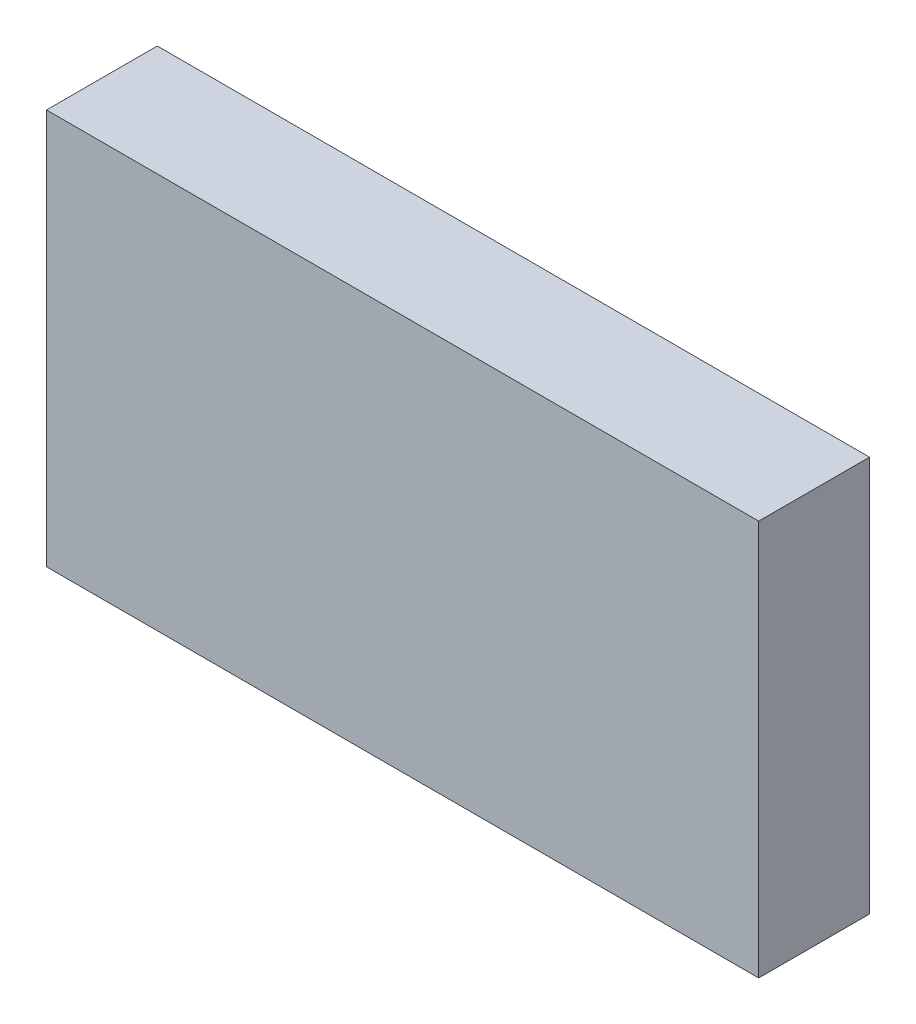
from build123d import *

# Parameters (mm, degrees)
PEDOUTLINE_W               = 114.3
PEDOUTLINE_H               = 63.5
PEDOUTLINE_THICKNESS_DEPTH = 17.78


with BuildPart() as part:
    # PedOutline → PedOutline_Thickness (new body)
    with BuildSketch(Plane.XY):
        with Locations((11574.991666666, -5688.0125)):
            Rectangle(PEDOUTLINE_W, PEDOUTLINE_H)
    extrude(amount=-PEDOUTLINE_THICKNESS_DEPTH)


solid = part.part
